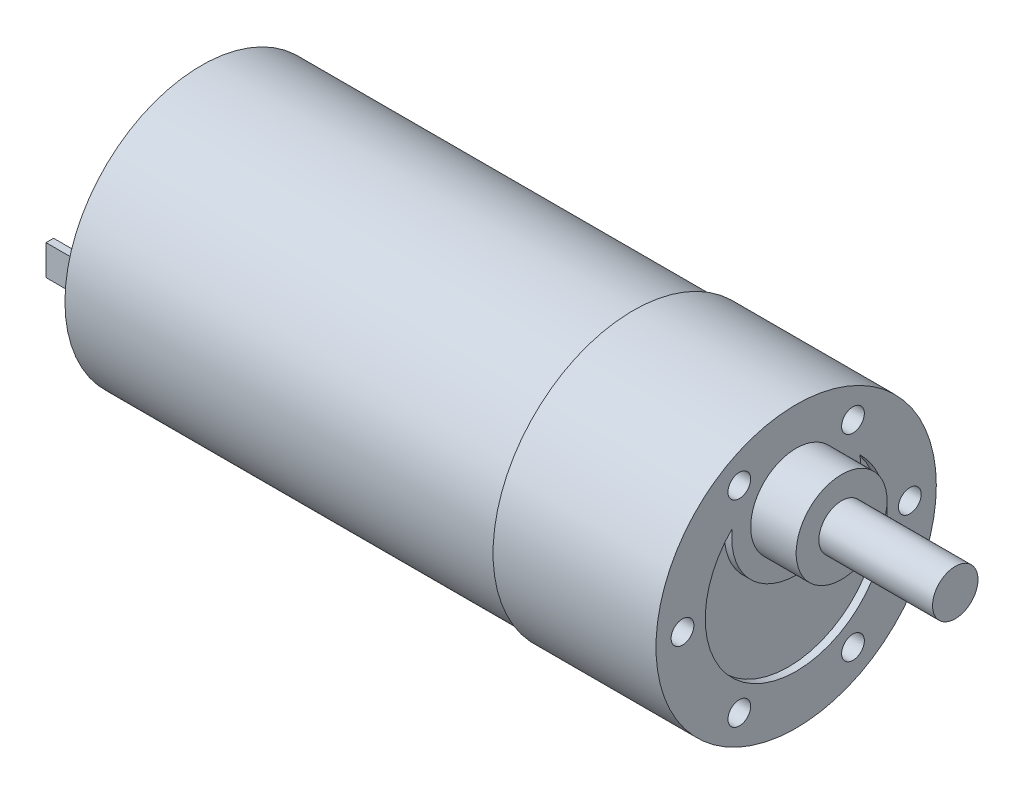
from build123d import *

# Parameters (mm, degrees)
SKETCH1_R           = 18.5
BOSS_EXTRUDE1_DEPTH = 21.5
SKETCH2_R           = 18
BOSS_EXTRUDE2_DEPTH = 57
SKETCH3_W           = 1
SKETCH3_H           = 4
BOSS_EXTRUDE3_DEPTH = 6
SKETCH4_R           = 6
BOSS_EXTRUDE4_DEPTH = 6
SKETCH5_R           = 3
BOSS_EXTRUDE5_DEPTH = 15
CUT_EXTRUDE1_DEPTH  = 1
SKETCH7_R           = 1.5
CUT_EXTRUDE2_DEPTH  = 5


with BuildPart() as part:
    # Sketch1 → Boss-Extrude1 (new body)
    with BuildSketch(Plane(origin=(0, 0, 0), x_dir=(0, 0, -1), z_dir=(1, 0, 0))):
        Circle(SKETCH1_R)
    extrude(amount=BOSS_EXTRUDE1_DEPTH)

    # Sketch2 → Boss-Extrude2 (add)
    with BuildSketch(Plane.ZY):
        Circle(SKETCH2_R)
    extrude(amount=BOSS_EXTRUDE2_DEPTH)

    # Sketch3 → Boss-Extrude3 (add)
    with BuildSketch(Plane.ZY.offset(57)):
        with Locations((-14, 0)):
            Rectangle(SKETCH3_W, SKETCH3_H)
        with Locations((14, 0)):
            Rectangle(SKETCH3_W, SKETCH3_H)
    extrude(amount=BOSS_EXTRUDE3_DEPTH)

    # Sketch4 → Boss-Extrude4 (add)
    with BuildSketch(Plane(origin=(21.5, 0, 0), x_dir=(0, 0, -1), z_dir=(1, 0, 0))):
        with Locations((0, 7.5)):
            Circle(SKETCH4_R)
    extrude(amount=BOSS_EXTRUDE4_DEPTH)

    # Sketch5 → Boss-Extrude5 (add)
    with BuildSketch(Plane(origin=(27.5, 0, 0), x_dir=(0, 0, -1), z_dir=(1, 0, 0))):
        with Locations((0, 7.5)):
            Circle(SKETCH5_R)
    extrude(amount=BOSS_EXTRUDE5_DEPTH)

    # Sketch6 → Cut-Extrude1 (cut)
    with BuildSketch(Plane(origin=(21.5, 0, 0), x_dir=(0, 0, -1), z_dir=(1, 0, 0))):
        with BuildLine():
            ThreePointArc((-8.436955744, 8.533333333), (-4.623663649, -11.073469847), (12, 0))
            ThreePointArc((12, 0), (11.073469847, 4.623663649), (8.436955744, 8.533333333))
            ThreePointArc((8.436955744, 8.533333333), (8.484224296, 8.017627365), (8.5, 7.5))
            ThreePointArc((8.5, 7.5), (-0.517627365, -0.984224296), (-8.436955744, 8.533333333))
        make_face()
    extrude(amount=-CUT_EXTRUDE1_DEPTH, mode=Mode.SUBTRACT)

    # Sketch7 → Cut-Extrude2 (cut)
    with BuildSketch(Plane(origin=(21.5, 0, 0), x_dir=(0, 0, -1), z_dir=(1, 0, 0))):
        with Locations((-15, 0)):
            Circle(SKETCH7_R)
        with Locations((-7.5, 12.990381057)):
            Circle(SKETCH7_R)
        with Locations((7.5, 12.990381057)):
            Circle(SKETCH7_R)
        with Locations((15, 0)):
            Circle(SKETCH7_R)
        with Locations((7.5, -12.990381057)):
            Circle(SKETCH7_R)
        with Locations((-7.5, -12.990381057)):
            Circle(SKETCH7_R)
    extrude(amount=-CUT_EXTRUDE2_DEPTH, mode=Mode.SUBTRACT)


solid = part.part
